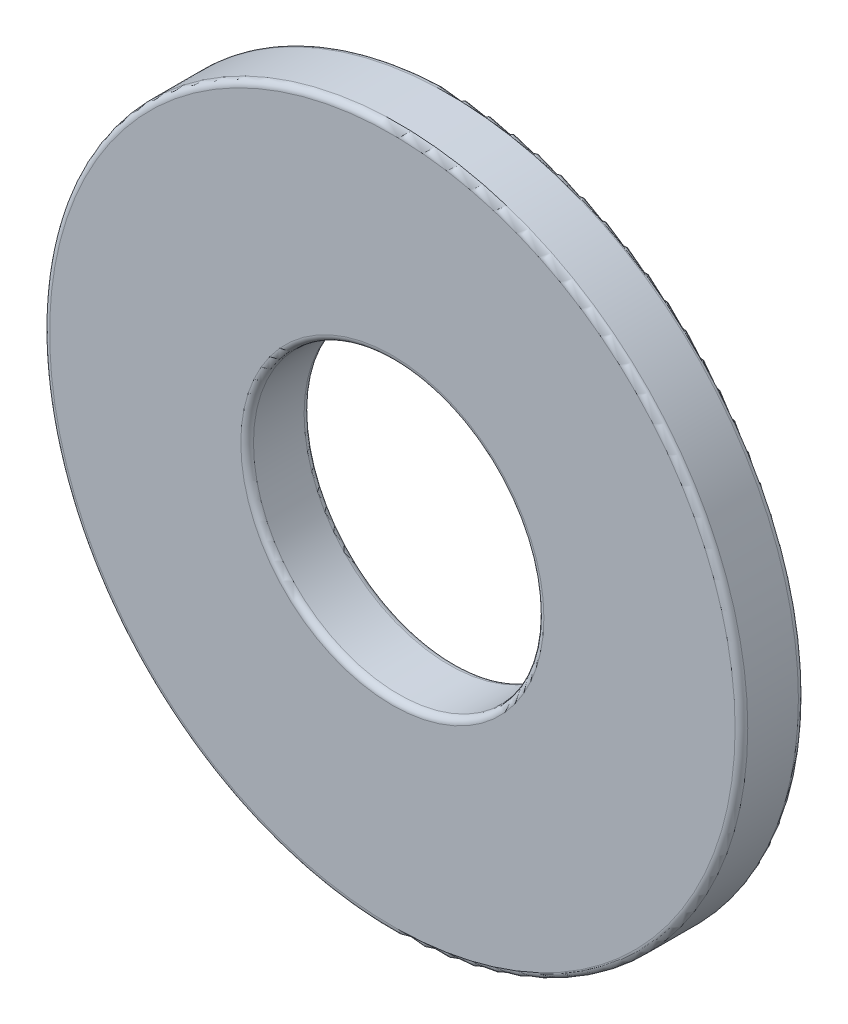
from build123d import *

# Parameters (mm, degrees)
SKETCH3_R                = 9.525
SKETCH3_R_2              = 3.9624
BOSS_EXTRUDE1_DEPTH      = 0.8636
BOSS_EXTRUDE1_DEPTH_BACK = 0.8636
FILLET1_R                = 0.17272


with BuildPart() as part:
    # Sketch3 → Boss-Extrude1 (new body, two sides)
    with BuildSketch(Plane.XY) as boss_extrude1_sk:
        Circle(SKETCH3_R)
        Circle(SKETCH3_R_2, mode=Mode.SUBTRACT)
    extrude(amount=BOSS_EXTRUDE1_DEPTH)
    extrude(boss_extrude1_sk.sketch, amount=-BOSS_EXTRUDE1_DEPTH_BACK)

    # Fillet1
    fillet1_edges = [part.edges().sort_by_distance(p)[0] for p in [
        (-9.525, 0, -0.8636),
        (-3.9624, 0, -0.8636),
        (-9.525, 0, 0.8636),
        (-3.9624, 0, 0.8636),
    ]]
    fillet(fillet1_edges, radius=FILLET1_R)


solid = part.part
